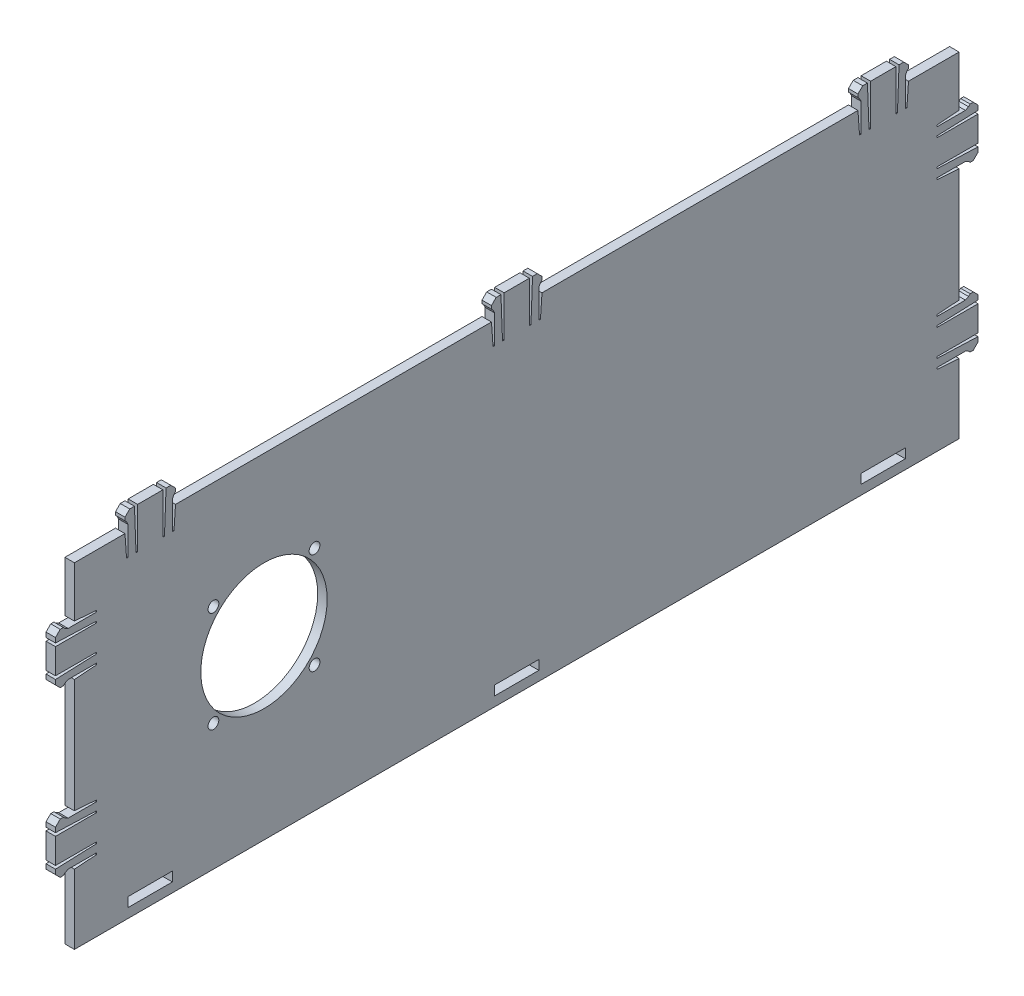
from build123d import *

# Parameters (mm, degrees)
BOSS_EXTRUDE1_DEPTH = 3
SKETCH3_W           = 14
SKETCH3_H           = 3
CUT_EXTRUDE1_DEPTH  = 3
SKETCH7_R           = 20
CUT_EXTRUDE2_DEPTH  = 3
SKETCH9_R           = 1.7
CUT_EXTRUDE3_DEPTH  = 3


with BuildPart() as part:
    # Sketch1 → Boss-Extrude1 (new body)
    with BuildSketch(Plane(origin=(0, 0, 0), x_dir=(0, 0, -1), z_dir=(1, 0, 0))):
        Polygon((-140, 34), (-140, 50), (-124, 50), (-123.5, 42.997828908), (-123, 42.997828908), (-123, 51.997828908), (-123.5, 52.997828908), (-124, 53.497828908), (-124, 54.497828908), (-122.5, 55.997828908), (-121, 55.997828908), (-120.5, 42.997828908), (-120, 42.997828908), (-120, 55.997828908), (-112, 55.997828908), (-112, 42.997828908), (-111.5, 42.997828908), (-111, 55.997828908), (-109.5, 55.997828908), (-108, 54.497828908), (-108, 53.497828908), (-108.5, 52.997828908), (-109, 51.997828908), (-109, 42.997828908), (-108.5, 42.997828908), (-108, 50), (-8, 50), (-7.5, 42.997828908), (-7, 42.997828908), (-7, 51.997828908), (-7.5, 52.997828908), (-8, 53.497828908), (-8, 54.497828908), (-6.5, 55.997828908), (-5, 55.997828908), (-4.5, 42.997828908), (-4, 42.997828908), (-4, 55.997828908), (4, 55.997828908), (4, 42.997828908), (4.5, 42.997828908), (5, 55.997828908), (6.5, 55.997828908), (8, 54.497828908), (8, 53.497828908), (7.5, 52.997828908), (7, 51.997828908), (7, 42.997828908), (7.5, 42.997828908), (8, 50), (108, 50), (108.5, 42.997828908), (109, 42.997828908), (109, 51.997828908), (108.5, 52.997828908), (108, 53.497828908), (108, 54.497828908), (109.5, 55.997828908), (111, 55.997828908), (111.5, 42.997828908), (112, 42.997828908), (112, 55.997828908), (120, 55.997828908), (120, 42.997828908), (120.5, 42.997828908), (121, 55.997828908), (122.5, 55.997828908), (124, 54.497828908), (124, 53.497828908), (123.5, 52.997828908), (123, 51.997828908), (123, 42.997828908), (123.5, 42.997828908), (124, 50), (140, 50), (140, 34), (132.997828908, 33.5), (132.997828908, 33), (141.997828908, 33), (142.997828908, 33.5), (143.497828908, 34), (144.497828908, 34), (145.997828908, 32.5), (145.997828908, 31), (132.997828908, 30.5), (132.997828908, 30), (145.997828908, 30), (145.997828908, 22), (132.997828908, 22), (132.997828908, 21.5), (145.997828908, 21), (145.997828908, 19.5), (144.497828908, 18), (143.497828908, 18), (142.997828908, 18.5), (141.997828908, 19), (132.997828908, 19), (132.997828908, 18.5), (140, 18), (140, -18), (132.997828908, -18.5), (132.997828908, -19), (141.997828908, -19), (142.997828908, -18.5), (143.497828908, -18), (144.497828908, -18), (145.997828908, -19.5), (145.997828908, -21), (132.997828908, -21.5), (132.997828908, -22), (145.997828908, -22), (145.997828908, -30), (132.997828908, -30), (132.997828908, -30.5), (145.997828908, -31), (145.997828908, -32.5), (144.497828908, -34), (143.497828908, -34), (142.997828908, -33.5), (141.997828908, -33), (132.997828908, -33), (132.997828908, -33.5), (140, -34), (140, -56), (-140, -56), (-140, -34), (-132.997828908, -33.5), (-132.997828908, -33), (-141.997828908, -33), (-142.997828908, -33.5), (-143.497828908, -34), (-144.497828908, -34), (-145.997828908, -32.5), (-145.997828908, -31), (-132.997828908, -30.5), (-132.997828908, -30), (-145.997828908, -30), (-145.997828908, -22), (-132.997828908, -22), (-132.997828908, -21.5), (-145.997828908, -21), (-145.997828908, -19.5), (-144.497828908, -18), (-143.497828908, -18), (-142.997828908, -18.5), (-141.997828908, -19), (-132.997828908, -19), (-132.997828908, -18.5), (-140, -18), (-140, 18), (-132.997828908, 18.5), (-132.997828908, 19), (-141.997828908, 19), (-142.997828908, 18.5), (-143.497828908, 18), (-144.497828908, 18), (-145.997828908, 19.5), (-145.997828908, 21), (-132.997828908, 21.5), (-132.997828908, 22), (-145.997828908, 22), (-145.997828908, 30), (-132.997828908, 30), (-132.997828908, 30.5), (-145.997828908, 31), (-145.997828908, 32.5), (-144.497828908, 34), (-143.497828908, 34), (-142.997828908, 33.5), (-141.997828908, 33), (-132.997828908, 33), (-132.997828908, 33.5), align=None)
    extrude(amount=BOSS_EXTRUDE1_DEPTH)

    # Sketch3 → Cut-Extrude1 (cut)
    with BuildSketch(Plane(origin=(3, 0, 0), x_dir=(0, 0, -1), z_dir=(1, 0, 0))):
        with Locations((-116, -51.5)):
            Rectangle(SKETCH3_W, SKETCH3_H)
        with Locations((0, -51.5)):
            Rectangle(SKETCH3_W, SKETCH3_H)
        with Locations((116, -51.5)):
            Rectangle(SKETCH3_W, SKETCH3_H)
    extrude(amount=-CUT_EXTRUDE1_DEPTH, mode=Mode.SUBTRACT)

    # Sketch7 → Cut-Extrude2 (cut)
    with BuildSketch(Plane(origin=(3, 0, 0), x_dir=(0, 0, -1), z_dir=(1, 0, 0))):
        with Locations((-80, 0)):
            Circle(SKETCH7_R)
    extrude(amount=-CUT_EXTRUDE2_DEPTH, mode=Mode.SUBTRACT)

    # Sketch9 → Cut-Extrude3 (cut)
    with BuildSketch(Plane(origin=(3, 0, 0), x_dir=(0, 0, -1), z_dir=(1, 0, 0))):
        with Locations((-96, 16)):
            Circle(SKETCH9_R)
        with Locations((-64, 16)):
            Circle(SKETCH9_R)
        with Locations((-64, -16)):
            Circle(SKETCH9_R)
        with Locations((-96, -16)):
            Circle(SKETCH9_R)
    extrude(amount=-CUT_EXTRUDE3_DEPTH, mode=Mode.SUBTRACT)


solid = part.part
